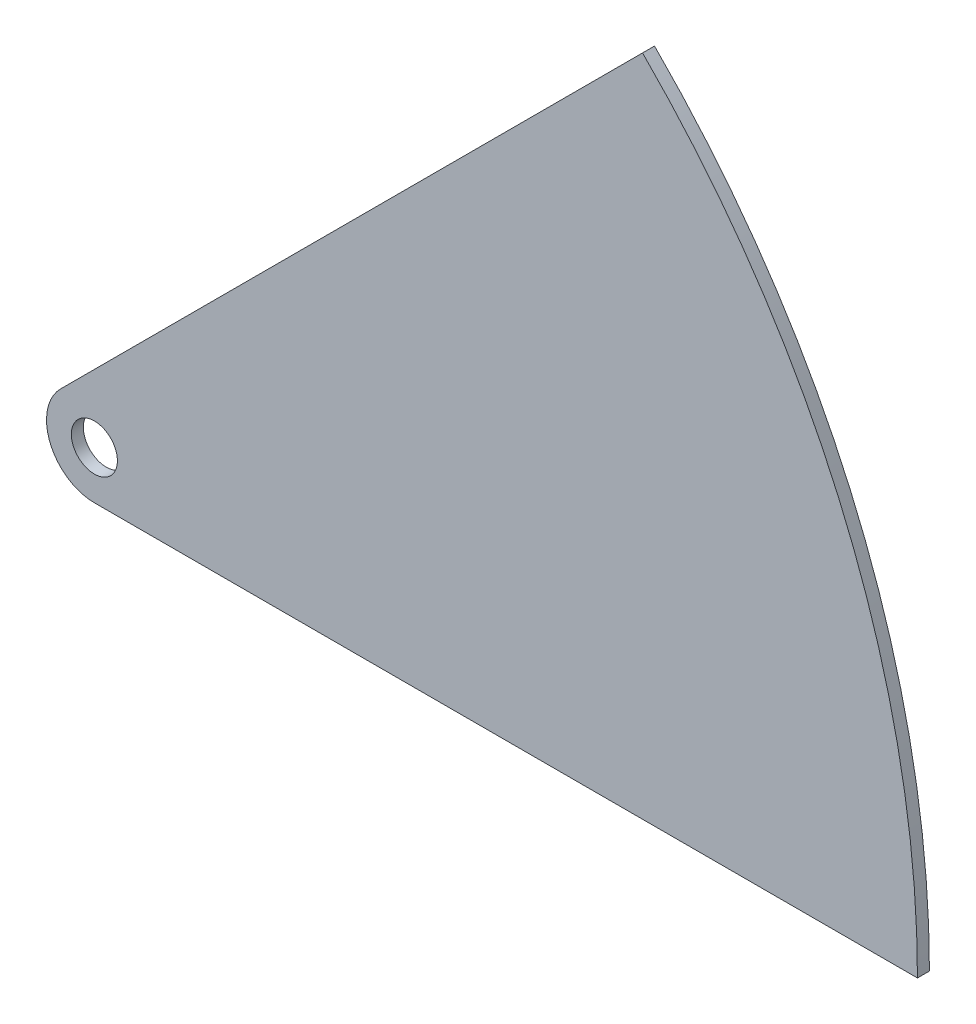
from build123d import *

# Parameters (mm, degrees)
SKETCH2_R           = 6.1087
BOSS_EXTRUDE1_DEPTH = 3.175


with BuildPart() as part:
    # Sketch2 → Boss-Extrude1 (new body)
    with BuildSketch(Plane.XY):
        with BuildLine():
            Line((-8.980256121, 8.980256121), (145.480149161, 163.440661403))
            ThreePointArc((145.480149161, 163.440661403), (199.478352556, 82.626639029), (218.44, -12.7))
            Line((218.44, -12.7), (0, -12.7))
            ThreePointArc((0, -12.7), (-11.733270063, -4.860079591), (-8.980256121, 8.980256121))
        make_face()
        Circle(SKETCH2_R, mode=Mode.SUBTRACT)
    extrude(amount=BOSS_EXTRUDE1_DEPTH)


solid = part.part
